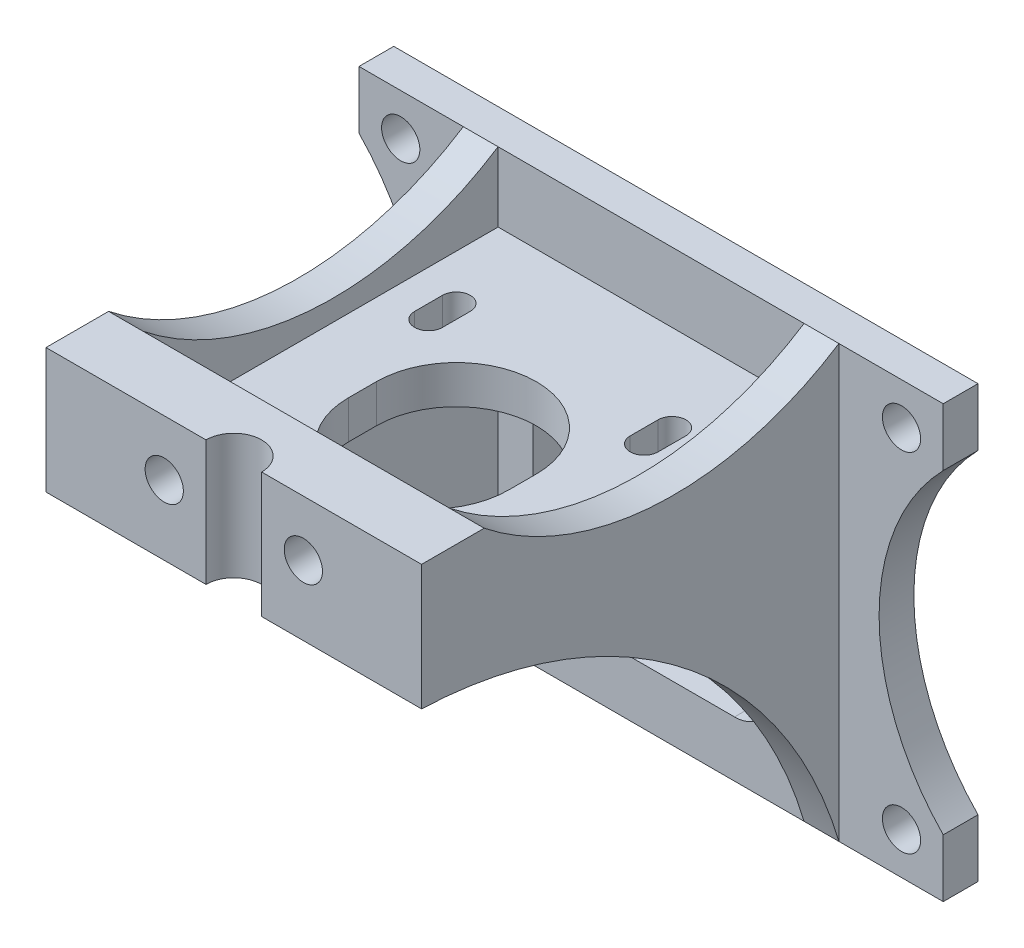
from build123d import *

# Parameters (mm, degrees)
BOSS_EXTRUDE1_DEPTH      = 42
BOSS_EXTRUDE1_DEPTH_BACK = 42
SKETCH2_W                = 15
SKETCH2_H                = 2.5
SKETCH2_R                = 2.75
CUT_EXTRUDE1_DEPTH       = 100.161484458
SKETCH3_R                = 4
SKETCH3_W                = 15
SKETCH3_H                = 60
CUT_EXTRUDE2_DEPTH       = 101.743486312
SKETCH4_W                = 44
SKETCH4_H                = 46.5
CUT_EXTRUDE3_DEPTH       = 60
CUT_EXTRUDE4_DEPTH       = 10
CUT_EXTRUDE4_DEPTH_BACK  = 10
SKETCH5_W                = 44
SKETCH5_H                = 51
SKETCH6_R                = 2.75
CUT_EXTRUDE5_DEPTH       = 4.6


with BuildPart() as part:
    # Sketch1 → Boss-Extrude1 (new, two sides: drawn at the far end of the back side and taken through both)
    with BuildSketch(Plane(origin=(0, 0, 0), x_dir=(0, 0, -1), z_dir=(1, 0, 0)).offset(-BOSS_EXTRUDE1_DEPTH_BACK)):
        with BuildLine():
            Line((0, 0), (0, -62))
            Line((0, -62), (-5, -62))
            ThreePointArc((-5, -62), (-27.506882202, -29.081460906), (-65, -15.5))
            Line((-65, -15.5), (-65, 2.5))
            Line((-65, 2.5), (-56, 2.5))
            ThreePointArc((-56, 2.5), (-30.901836055, -6.947455525), (-5, 0))
            Line((-5, 0), (0, 0))
        make_face()
    extrude(amount=BOSS_EXTRUDE1_DEPTH + BOSS_EXTRUDE1_DEPTH_BACK)

    # Sketch2 → Cut-Extrude1 (cut, through all)
    with BuildSketch(Plane(origin=(0, 0, 0), x_dir=(-1, 0, 0), z_dir=(0, 0, -1))):
        with BuildLine():
            ThreePointArc((-17, -49), (-15.535533906, -52.535533906), (-12, -54))
            Line((-12, -54), (12, -54))
            ThreePointArc((12, -54), (15.535533906, -52.535533906), (17, -49))
            Line((17, -49), (17, -25.5))
            ThreePointArc((17, -25.5), (15.535533906, -21.964466094), (12, -20.5))
            Line((12, -20.5), (-12, -20.5))
            ThreePointArc((-12, -20.5), (-15.535533906, -21.964466094), (-17, -25.5))
            Line((-17, -25.5), (-17, -49))
        make_face()
        with Locations((-34.5, 1.25)):
            Rectangle(SKETCH2_W, SKETCH2_H)
        with BuildLine():
            Line((42, -53.6792), (42, -8.3208))
            ThreePointArc((42, -8.3208), (32.778829166, -31), (42, -53.6792))
        make_face()
        with Locations((34.5, 1.25)):
            Rectangle(SKETCH2_W, SKETCH2_H)
        with BuildLine():
            ThreePointArc((-42, -53.6792), (-32.778829166, -31), (-42, -8.3208))
            Line((-42, -8.3208), (-42, -53.6792))
        make_face()
        with Locations((-36, -6)):
            Circle(SKETCH2_R)
        with Locations((36, -6)):
            Circle(SKETCH2_R)
        with Locations((36, -56)):
            Circle(SKETCH2_R)
        with Locations((-36, -56)):
            Circle(SKETCH2_R)
    extrude(amount=-CUT_EXTRUDE1_DEPTH, mode=Mode.SUBTRACT)

    # Sketch3 → Cut-Extrude2 (cut, through all)
    with BuildSketch(Plane(origin=(0, -62, 0), x_dir=(-1, 0, 0), z_dir=(0, -1, 0))):
        with Locations((0, -65)):
            Circle(SKETCH3_R)
        with Locations((34.5, -35)):
            Rectangle(SKETCH3_W, SKETCH3_H)
        with Locations((-34.5, -35)):
            Rectangle(SKETCH3_W, SKETCH3_H)
        with BuildLine():
            Line((11.5, -33), (11.5, -37))
            ThreePointArc((11.5, -37), (0, -48.5), (-11.5, -37))
            Line((-11.5, -37), (-11.5, -33))
            ThreePointArc((-11.5, -33), (0, -21.5), (11.5, -33))
        make_face()
        with BuildLine():
            Line((17.5, -48.5), (17.5, -52.5))
            ThreePointArc((17.5, -52.5), (15.5, -54.5), (13.5, -52.5))
            Line((13.5, -52.5), (13.5, -48.5))
            ThreePointArc((13.5, -48.5), (15.5, -46.5), (17.5, -48.5))
        make_face()
        with BuildLine():
            Line((17.5, -17.5), (17.5, -21.5))
            ThreePointArc((17.5, -21.5), (15.5, -23.5), (13.5, -21.5))
            Line((13.5, -21.5), (13.5, -17.5))
            ThreePointArc((13.5, -17.5), (15.5, -15.5), (17.5, -17.5))
        make_face()
        with BuildLine():
            Line((-17.5, -17.5), (-17.5, -21.5))
            ThreePointArc((-17.5, -21.5), (-15.5, -23.5), (-13.5, -21.5))
            Line((-13.5, -21.5), (-13.5, -17.5))
            ThreePointArc((-13.5, -17.5), (-15.5, -15.5), (-17.5, -17.5))
        make_face()
        with BuildLine():
            Line((-17.5, -48.5), (-17.5, -52.5))
            ThreePointArc((-17.5, -52.5), (-15.5, -54.5), (-13.5, -52.5))
            Line((-13.5, -52.5), (-13.5, -48.5))
            ThreePointArc((-13.5, -48.5), (-15.5, -46.5), (-17.5, -48.5))
        make_face()
    extrude(amount=-CUT_EXTRUDE2_DEPTH, mode=Mode.SUBTRACT)

    # Sketch4 → Cut-Extrude3 (cut)
    with BuildSketch(Plane.XY.offset(65)):
        with Locations((0, -38.75)):
            Rectangle(SKETCH4_W, SKETCH4_H)
    extrude(amount=-CUT_EXTRUDE3_DEPTH, mode=Mode.SUBTRACT)

    # Sketch5 → Cut-Extrude4 (cut, two sides: drawn at the far end of the back side and taken through both)
    with BuildSketch(Plane(origin=(0, 0, 0), x_dir=(1, 0, 0), z_dir=(0, 1, 0)).offset(-CUT_EXTRUDE4_DEPTH_BACK)):
        with Locations((0, -30.5)):
            Rectangle(SKETCH5_W, SKETCH5_H)
    extrude(amount=CUT_EXTRUDE4_DEPTH + CUT_EXTRUDE4_DEPTH_BACK, mode=Mode.SUBTRACT)

    # Sketch6 → Cut-Extrude5 (cut)
    with BuildSketch(Plane.XY.offset(65)):
        with Locations((-10, -5.5)):
            Circle(SKETCH6_R)
        with Locations((10, -5.5)):
            Circle(SKETCH6_R)
    extrude(amount=-CUT_EXTRUDE5_DEPTH, mode=Mode.SUBTRACT)


solid = part.part
